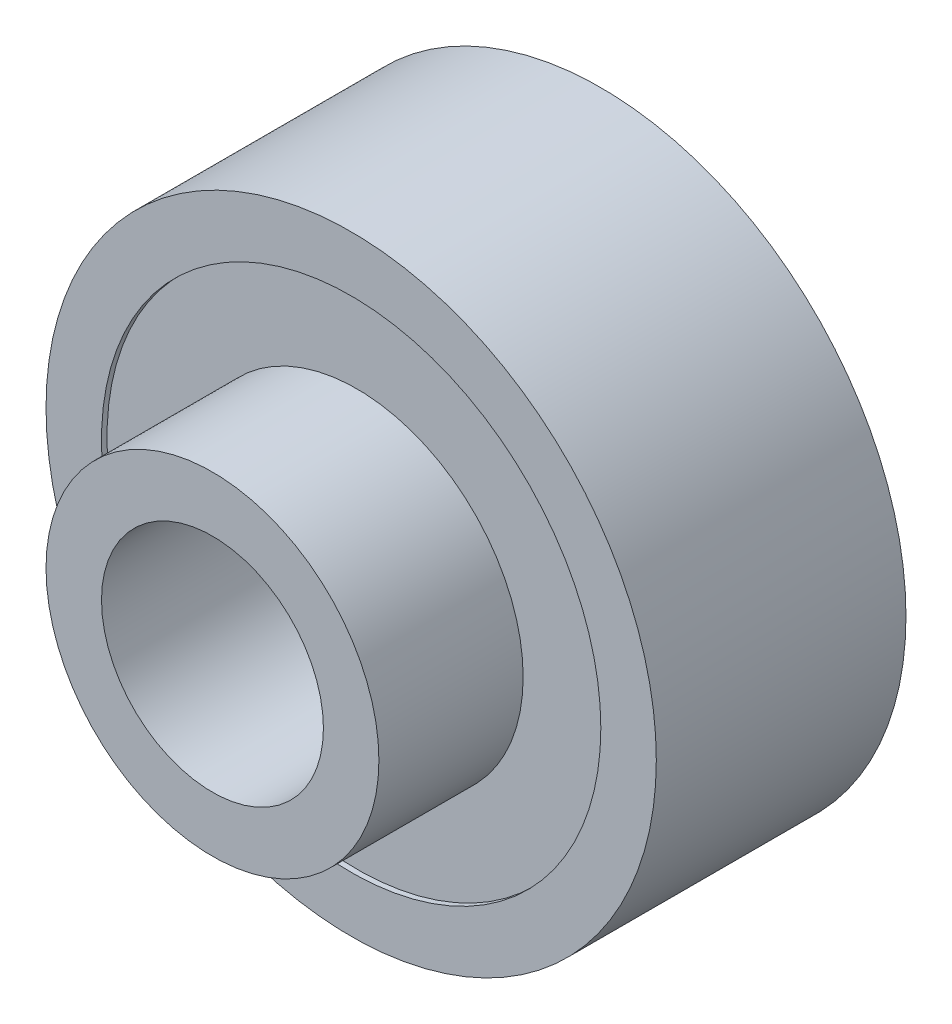
from build123d import *

# Parameters (mm, degrees)
SKETCH1_R           = 11
BOSS_EXTRUDE1_DEPTH = 9
SKETCH2_R           = 4
CUT_EXTRUDE1_DEPTH  = 10
SKETCH3_R           = 9
SKETCH3_R_2         = 6
CUT_EXTRUDE2_DEPTH  = 0.2
SKETCH4_R           = 9
SKETCH4_R_2         = 6
CUT_EXTRUDE3_DEPTH  = 0.2
SKETCH5_R           = 6
SKETCH5_R_2         = 4
BOSS_EXTRUDE2_DEPTH = 5


with BuildPart() as part:
    # Sketch1 → Boss-Extrude1 (new body)
    with BuildSketch(Plane.XY):
        Circle(SKETCH1_R)
    extrude(amount=BOSS_EXTRUDE1_DEPTH)

    # Sketch2 → Cut-Extrude1 (cut, through all)
    with BuildSketch(Plane.XY.offset(9)):
        Circle(SKETCH2_R)
    extrude(amount=-CUT_EXTRUDE1_DEPTH, mode=Mode.SUBTRACT)

    # Sketch3 → Cut-Extrude2 (cut)
    with BuildSketch(Plane.XY.offset(9)):
        Circle(SKETCH3_R)
        Circle(SKETCH3_R_2, mode=Mode.SUBTRACT)
    extrude(amount=-CUT_EXTRUDE2_DEPTH, mode=Mode.SUBTRACT)

    # Sketch4 → Cut-Extrude3 (cut)
    with BuildSketch(Plane(origin=(0, 0, 0), x_dir=(-1, 0, 0), z_dir=(0, 0, -1))):
        Circle(SKETCH4_R)
        Circle(SKETCH4_R_2, mode=Mode.SUBTRACT)
    extrude(amount=-CUT_EXTRUDE3_DEPTH, mode=Mode.SUBTRACT)

    # Sketch5 → Boss-Extrude2 (add)
    with BuildSketch(Plane.XY.offset(9)):
        Circle(SKETCH5_R)
        Circle(SKETCH5_R_2, mode=Mode.SUBTRACT)
    extrude(amount=BOSS_EXTRUDE2_DEPTH)


solid = part.part
